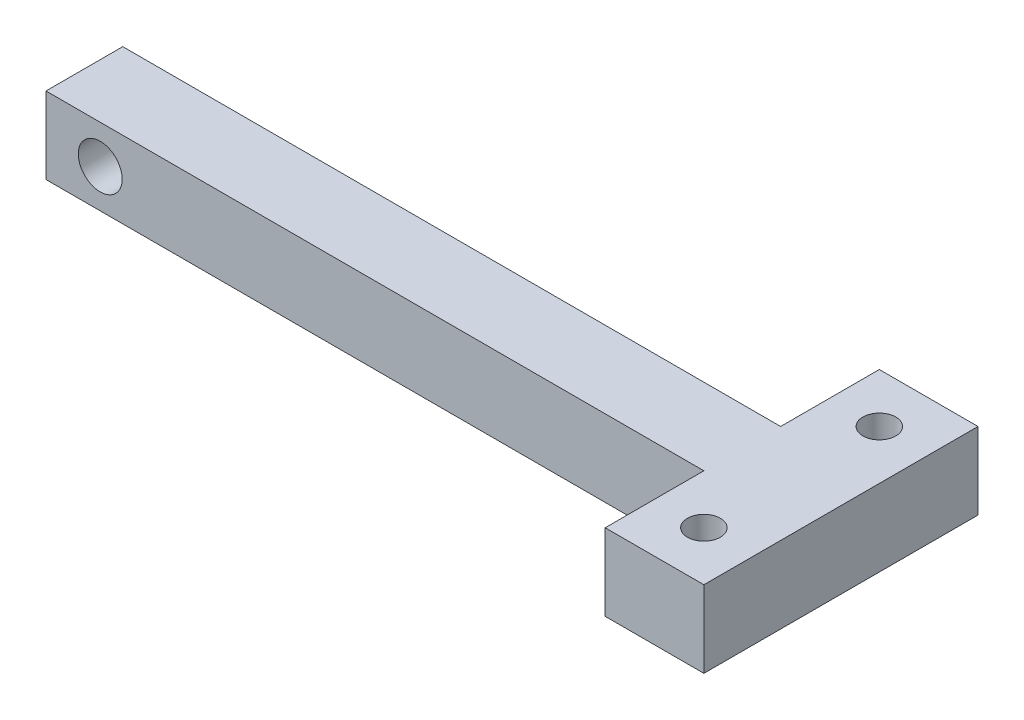
from build123d import *

# Parameters (mm, degrees)
SKETCH1_R           = 1.5
SKETCH1_W           = 60
SKETCH1_H           = 7
BOSS_EXTRUDE1_DEPTH = 7
SKETCH2_R           = 2
CUT_EXTRUDE1_DEPTH  = 7


with BuildPart() as part:
    # Sketch1 → Boss-Extrude1 (new body)
    with BuildSketch(Plane(origin=(0, 0, 0), x_dir=(1, 0, 0), z_dir=(0, 1, 0))):
        Polygon((60, 7), (60, 0), (60, -9), (69, -9), (69, 16), (60, 16), align=None)
        with Locations((64.5, -4.5)):
            Circle(SKETCH1_R, mode=Mode.SUBTRACT)
        with Locations((64.5, 11.5)):
            Circle(SKETCH1_R, mode=Mode.SUBTRACT)
        with Locations((30, 3.5)):
            Rectangle(SKETCH1_W, SKETCH1_H)
    extrude(amount=BOSS_EXTRUDE1_DEPTH)

    # Sketch2 → Cut-Extrude1 (cut)
    with BuildSketch(Plane(origin=(0, 0, -7), x_dir=(-1, 0, 0), z_dir=(0, 0, -1))):
        with Locations((-4.944972507, 3.5)):
            Circle(SKETCH2_R)
    extrude(amount=-CUT_EXTRUDE1_DEPTH, mode=Mode.SUBTRACT)


solid = part.part
